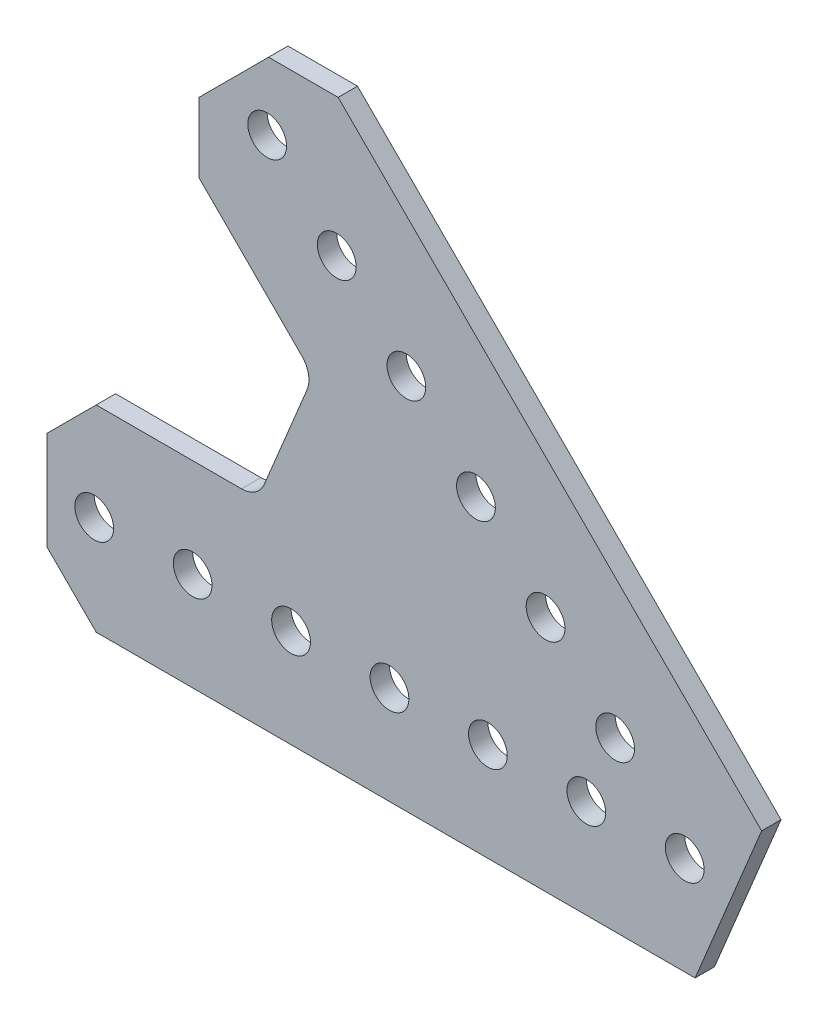
from build123d import *

# Parameters (mm, degrees)
SKETCH1_R           = 2.5
BOSS_EXTRUDE1_DEPTH = 2.5


with BuildPart() as part:
    # Sketch1 → Boss-Extrude1 (new body)
    with BuildSketch(Plane(origin=(0, 0, -1.25), x_dir=(-1, 0, 0), z_dir=(0, 0, -1))):
        with BuildLine():
            Line((-1.337750611, -12.7), (75.946, -12.7))
            Line((75.946, -12.7), (82.296, -6.35))
            Line((82.296, -6.35), (82.296, 6.35))
            Line((82.296, 6.35), (75.946, 12.7))
            Line((75.946, 12.7), (57.193204579, 12.7))
            ThreePointArc((57.193204579, 12.7), (55.429269089, 13.235083981), (54.259887063, 14.659980102))
            Line((54.259887063, 14.659980102), (48.733705431, 28.001362746))
            ThreePointArc((48.733705431, 28.001362746), (48.553029681, 29.835794416), (49.421958916, 31.461446674))
            Line((49.421958916, 31.461446674), (62.682187725, 44.721675483))
            Line((62.682187725, 44.721675483), (62.682187725, 53.701931604))
            Line((62.682187725, 53.701931604), (53.701931604, 62.682187725))
            Line((53.701931604, 62.682187725), (44.721675483, 62.682187725))
            Line((44.721675483, 62.682187725), (-9.92618865, 8.034323593))
            Line((-9.92618865, 8.034323593), (-1.337750611, -12.7))
        make_face()
        with Locations((12.7, 0)):
            Circle(SKETCH1_R, mode=Mode.SUBTRACT)
        with Locations((25.4, 0)):
            Circle(SKETCH1_R, mode=Mode.SUBTRACT)
        with Locations((38.1, 0)):
            Circle(SKETCH1_R, mode=Mode.SUBTRACT)
        with Locations((50.8, 0)):
            Circle(SKETCH1_R, mode=Mode.SUBTRACT)
        Circle(SKETCH1_R, mode=Mode.SUBTRACT)
        with Locations((76.2, 0)):
            Circle(SKETCH1_R, mode=Mode.SUBTRACT)
        with Locations((63.5, 0)):
            Circle(SKETCH1_R, mode=Mode.SUBTRACT)
        with Locations((53.881536726, 53.881536726)):
            Circle(SKETCH1_R, mode=Mode.SUBTRACT)
        with Locations((44.901280605, 44.901280605)):
            Circle(SKETCH1_R, mode=Mode.SUBTRACT)
        with Locations((35.921024484, 35.921024484)):
            Circle(SKETCH1_R, mode=Mode.SUBTRACT)
        with Locations((26.940768363, 26.940768363)):
            Circle(SKETCH1_R, mode=Mode.SUBTRACT)
        with Locations((17.960512242, 17.960512242)):
            Circle(SKETCH1_R, mode=Mode.SUBTRACT)
        with Locations((8.980256121, 8.980256121)):
            Circle(SKETCH1_R, mode=Mode.SUBTRACT)
    extrude(amount=-BOSS_EXTRUDE1_DEPTH)


solid = part.part
